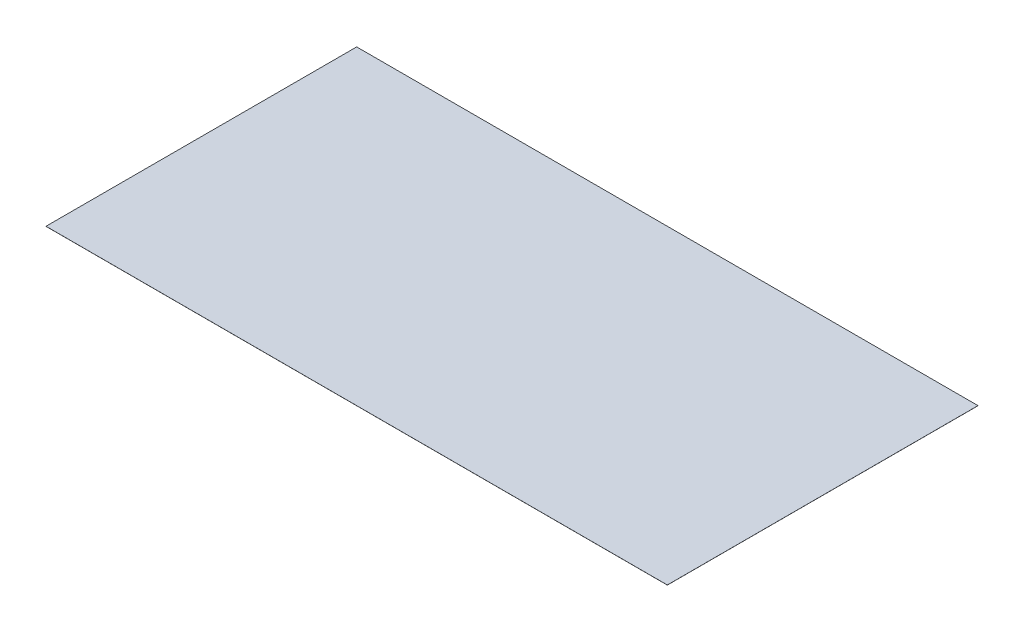
from build123d import *

# Parameters (mm, degrees)
SKETCH1_W           = 16459.2
SKETCH1_H           = 8229.6
BOSS_EXTRUDE1_DEPTH = 2.54


with BuildPart() as part:
    # Sketch1 → Boss-Extrude1 (new body)
    with BuildSketch(Plane(origin=(0, 0, 0), x_dir=(1, 0, 0), z_dir=(0, 1, 0))):
        with Locations((8229.6, 4114.8)):
            Rectangle(SKETCH1_W, SKETCH1_H)
    extrude(amount=BOSS_EXTRUDE1_DEPTH)


solid = part.part
